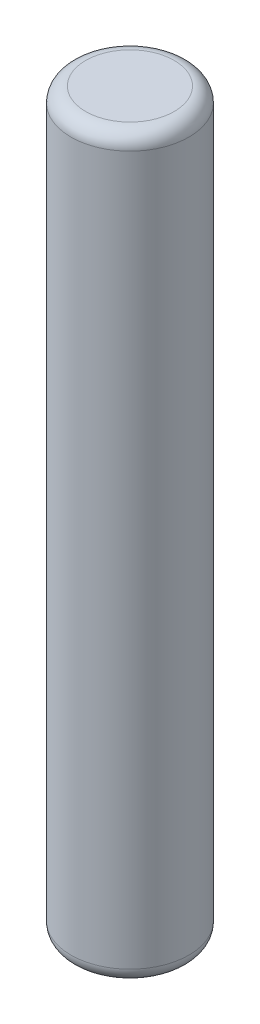
from build123d import *

# Parameters (mm, degrees)
SKETCH1_R           = 4
BOSS_EXTRUDE1_DEPTH = 50
FILLET1_R           = 1
FILLET2_R           = 1


with BuildPart() as part:
    # Sketch1 → Boss-Extrude1 (new body)
    with BuildSketch(Plane(origin=(0, 0, 0), x_dir=(1, 0, 0), z_dir=(0, 1, 0))):
        Circle(SKETCH1_R)
    extrude(amount=BOSS_EXTRUDE1_DEPTH)

    # Fillet1
    fillet1_edges = [part.edges().sort_by_distance(p)[0] for p in [
        (-4, 50, 0),
    ]]
    fillet(fillet1_edges, radius=FILLET1_R)

    # Fillet2
    fillet2_edges = [part.edges().sort_by_distance(p)[0] for p in [
        (-4, 0, 0),
    ]]
    fillet(fillet2_edges, radius=FILLET2_R)


solid = part.part
